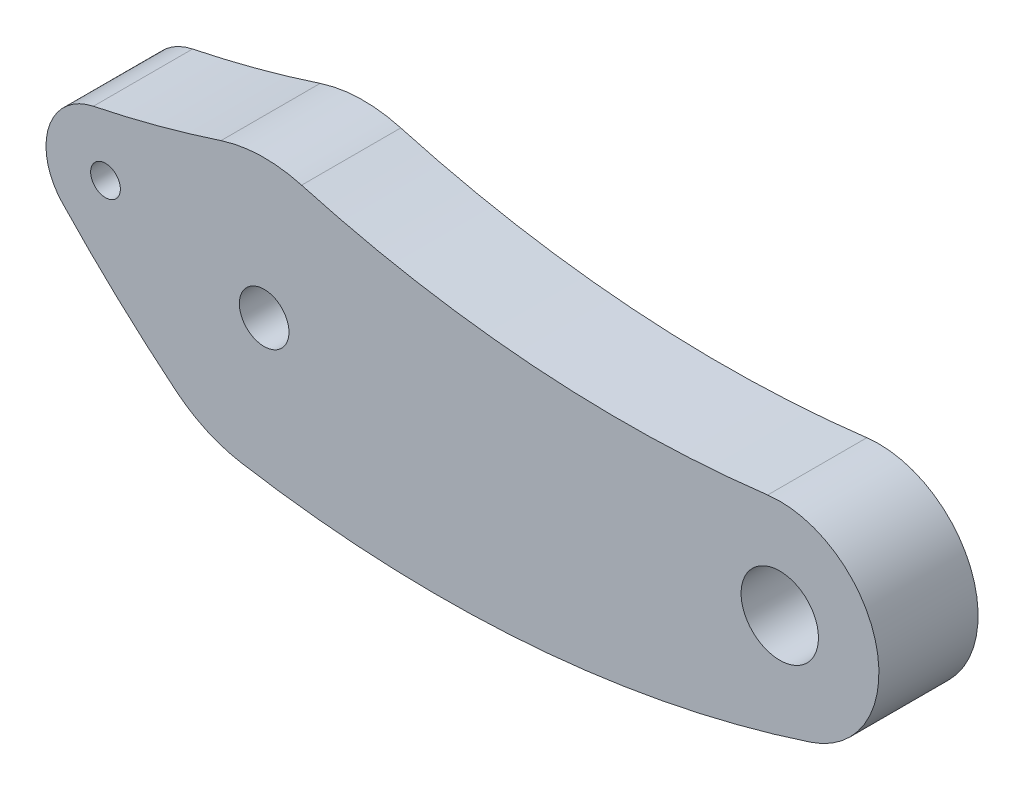
from build123d import *

# Parameters (mm, degrees)
SKETCH1_R           = 1.25
SKETCH1_R_2         = 1.95
SKETCH1_R_3         = 0.75
BOSS_EXTRUDE1_DEPTH = 5


with BuildPart() as part:
    # Sketch1 → Boss-Extrude1 (new body)
    with BuildSketch(Plane.XY):
        with BuildLine():
            ThreePointArc((-8.610955567, 4.937130112), (-10.861185503, 2.902007494), (-10.184976203, -0.055694285))
            ThreePointArc((-10.184976203, -0.055694285), (-7.393826535, -2.833777155), (-4.426449716, -5.422779998))
            ThreePointArc((-4.426449716, -5.422779998), (-2.893501985, -6.373981978), (-1.168359942, -6.901806651))
            ThreePointArc((-1.168359942, -6.901806651), (13.32656581, -7.575945982), (27.559440559, -4.750594188))
            ThreePointArc((27.559440559, -4.750594188), (30.879826902, 1.089628103), (25.390532544, 4.962715932))
            ThreePointArc((25.390532544, 4.962715932), (13.551436315, 4.686217454), (1.888633754, 6.740405221))
            ThreePointArc((1.888633754, 6.740405221), (-0.150298826, 6.998386261), (-2.176275648, 6.653106365))
            ThreePointArc((-2.176275648, 6.653106365), (-5.369789667, 5.705774168), (-8.610955567, 4.937130112))
        make_face()
        Circle(SKETCH1_R, mode=Mode.SUBTRACT)
        with Locations((26, 0)):
            Circle(SKETCH1_R_2, mode=Mode.SUBTRACT)
        with Locations((-8, 2)):
            Circle(SKETCH1_R_3, mode=Mode.SUBTRACT)
    extrude(amount=BOSS_EXTRUDE1_DEPTH)


solid = part.part
